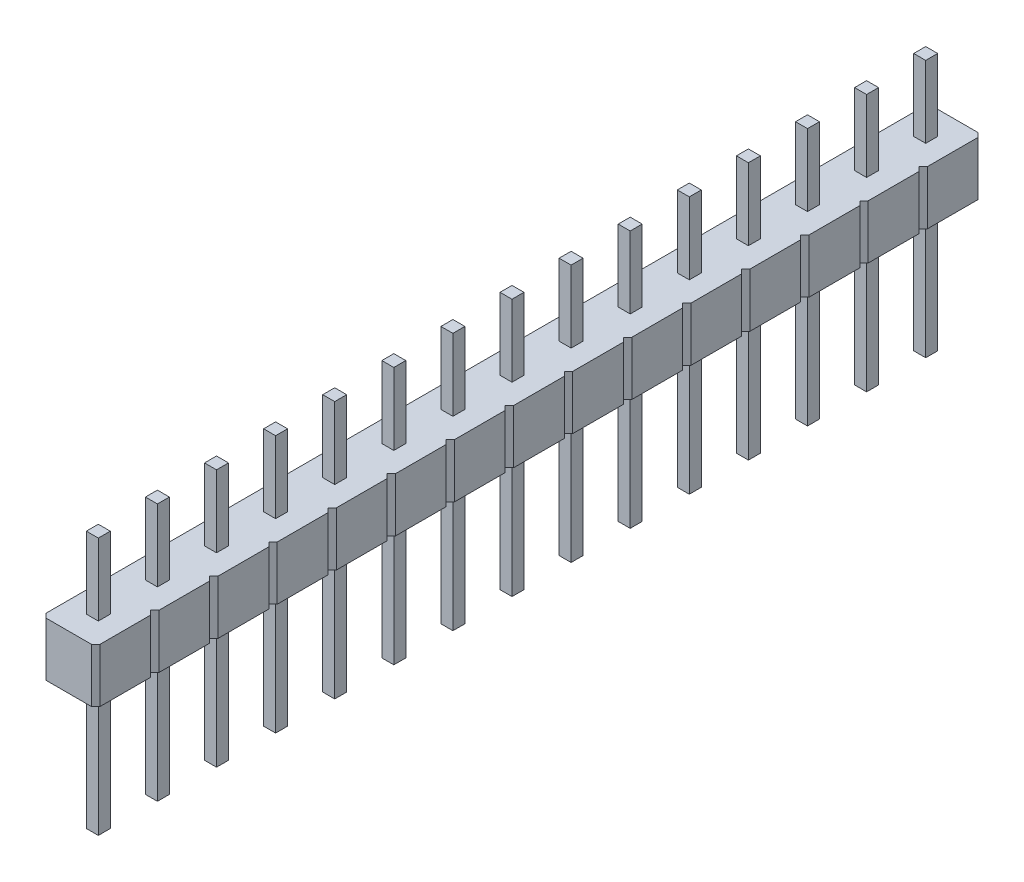
from build123d import *

# Parameters (mm, degrees)
SKETCH1_W                = 2.286
SKETCH1_H                = 37.592
BOSS_EXTRUDE1_DEPTH      = 2.286
SKETCH3_W                = 2.286
SKETCH3_H                = 35.085866667
CUT_EXTRUDE1_DEPTH       = 3.286
CHAMFER1_SIZE            = 0.1778
SKETCH2_W                = 0.508
SKETCH2_H                = 0.508
BOSS_EXTRUDE2_DEPTH      = 3.048
BOSS_EXTRUDE2_DEPTH_BACK = 7.874
LPATTERN1_COUNT          = 15
LPATTERN1_PITCH          = 2.506133333


with BuildPart() as part:
    # Sketch1 → Boss-Extrude1 (new body)
    with BuildSketch(Plane(origin=(0, 0, 0), x_dir=(1, 0, 0), z_dir=(0, 1, 0))):
        Rectangle(SKETCH1_W, SKETCH1_H)
    extrude(amount=BOSS_EXTRUDE1_DEPTH)

    # Sketch3 → Cut-Extrude1 (cut, through all)
    with BuildSketch(Plane(origin=(0, 2.286, 0), x_dir=(1, 0, 0), z_dir=(0, 1, 0))):
        with Locations((0, -1.253066667)):
            Rectangle(SKETCH3_W, SKETCH3_H)
    extrude(amount=-CUT_EXTRUDE1_DEPTH, mode=Mode.SUBTRACT)

    # Chamfer1
    chamfer1_edges = [part.edges().sort_by_distance(p)[0] for p in [
        (-1.143, 1.143, -16.289866667),
        (1.143, 1.143, -16.289866667),
        (-1.143, 1.143, -18.796),
        (1.143, 1.143, -18.796),
    ]]
    chamfer(chamfer1_edges, length=CHAMFER1_SIZE)

    # Sketch2 → Boss-Extrude2 (add, two sides)
    with BuildSketch(Plane(origin=(0, 2.286, 0), x_dir=(1, 0, 0), z_dir=(0, 1, 0))) as boss_extrude2_sk:
        with Locations((0, 17.543018)):
            Rectangle(SKETCH2_W, SKETCH2_H)
    extrude(amount=BOSS_EXTRUDE2_DEPTH)
    extrude(boss_extrude2_sk.sketch, amount=-BOSS_EXTRUDE2_DEPTH_BACK)


with BuildPart() as lpattern1_1:
    # LPattern1: pattern copy
    add(part.part.moved(Location(Vector(0, 0, 1) * (1 * LPATTERN1_PITCH))))


with BuildPart() as lpattern1_2:
    # LPattern1: pattern copy
    add(part.part.moved(Location(Vector(0, 0, 1) * (2 * LPATTERN1_PITCH))))


with BuildPart() as lpattern1_3:
    # LPattern1: pattern copy
    add(part.part.moved(Location(Vector(0, 0, 1) * (3 * LPATTERN1_PITCH))))


with BuildPart() as lpattern1_4:
    # LPattern1: pattern copy
    add(part.part.moved(Location(Vector(0, 0, 1) * (4 * LPATTERN1_PITCH))))


with BuildPart() as lpattern1_5:
    # LPattern1: pattern copy
    add(part.part.moved(Location(Vector(0, 0, 1) * (5 * LPATTERN1_PITCH))))


with BuildPart() as lpattern1_6:
    # LPattern1: pattern copy
    add(part.part.moved(Location(Vector(0, 0, 1) * (6 * LPATTERN1_PITCH))))


with BuildPart() as lpattern1_7:
    # LPattern1: pattern copy
    add(part.part.moved(Location(Vector(0, 0, 1) * (7 * LPATTERN1_PITCH))))


with BuildPart() as lpattern1_8:
    # LPattern1: pattern copy
    add(part.part.moved(Location(Vector(0, 0, 1) * (8 * LPATTERN1_PITCH))))


with BuildPart() as lpattern1_9:
    # LPattern1: pattern copy
    add(part.part.moved(Location(Vector(0, 0, 1) * (9 * LPATTERN1_PITCH))))


with BuildPart() as lpattern1_10:
    # LPattern1: pattern copy
    add(part.part.moved(Location(Vector(0, 0, 1) * (10 * LPATTERN1_PITCH))))


with BuildPart() as lpattern1_11:
    # LPattern1: pattern copy
    add(part.part.moved(Location(Vector(0, 0, 1) * (11 * LPATTERN1_PITCH))))


with BuildPart() as lpattern1_12:
    # LPattern1: pattern copy
    add(part.part.moved(Location(Vector(0, 0, 1) * (12 * LPATTERN1_PITCH))))


with BuildPart() as lpattern1_13:
    # LPattern1: pattern copy
    add(part.part.moved(Location(Vector(0, 0, 1) * (13 * LPATTERN1_PITCH))))


with BuildPart() as lpattern1_14:
    # LPattern1: pattern copy
    add(part.part.moved(Location(Vector(0, 0, 1) * (14 * LPATTERN1_PITCH))))


with BuildPart() as lpattern1_12_1:
    add(lpattern1_12.part)

    # Combine1: union LPattern1_5, LPattern1_10, LPattern1_3, LPattern1_8, LPattern1_13, LPattern1_1, LPattern1_6, LPattern1_11, LPattern1_4, LPattern1_9, LPattern1_14, LPattern1_2, part, LPattern1_7
    add(lpattern1_5.part)
    add(lpattern1_10.part)
    add(lpattern1_3.part)
    add(lpattern1_8.part)
    add(lpattern1_13.part)
    add(lpattern1_1.part)
    add(lpattern1_6.part)
    add(lpattern1_11.part)
    add(lpattern1_4.part)
    add(lpattern1_9.part)
    add(lpattern1_14.part)
    add(lpattern1_2.part)
    add(part.part)
    add(lpattern1_7.part)


solid = lpattern1_12_1.part
